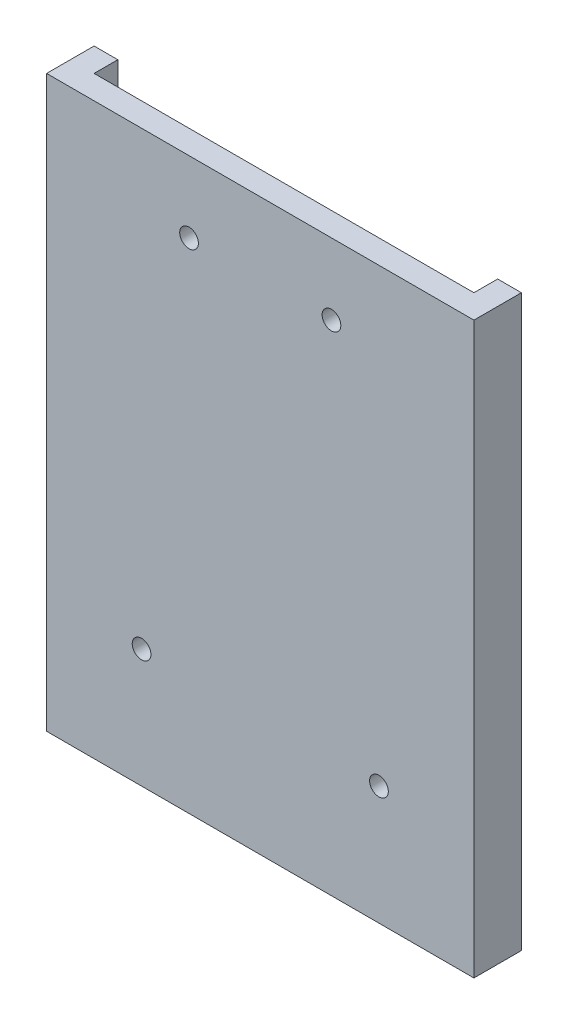
from build123d import *

# Parameters (mm, degrees)
SKETCH1_W           = 57.15
SKETCH1_H           = 6.35
BOSS_EXTRUDE1_DEPTH = 76.2
SKETCH2_W           = 50.8
SKETCH2_H           = 3.175
CUT_EXTRUDE1_DEPTH  = 73.025
SKETCH4_R           = 1.25
CUT_EXTRUDE2_DEPTH  = 4.175


with BuildPart() as part:
    # Sketch1 → Boss-Extrude1 (new body)
    with BuildSketch(Plane(origin=(0, 0, 0), x_dir=(1, 0, 0), z_dir=(0, 1, 0))):
        Rectangle(SKETCH1_W, SKETCH1_H)
    extrude(amount=BOSS_EXTRUDE1_DEPTH)

    # Sketch2 → Cut-Extrude1 (cut)
    with BuildSketch(Plane(origin=(0, 76.2, 0), x_dir=(1, 0, 0), z_dir=(0, 1, 0))):
        with Locations((0, 1.5875)):
            Rectangle(SKETCH2_W, SKETCH2_H)
    extrude(amount=-CUT_EXTRUDE1_DEPTH, mode=Mode.SUBTRACT)

    # Sketch4 → Cut-Extrude2 (cut, through all)
    with BuildSketch(Plane(origin=(0, 0, 0), x_dir=(-1, 0, 0), z_dir=(0, 0, -1))):
        with Locations((-9.525, 66.675)):
            Circle(SKETCH4_R)
        with Locations((9.525, 66.675)):
            Circle(SKETCH4_R)
        with Locations((-15.875, 15.875)):
            Circle(SKETCH4_R)
        with Locations((15.875, 15.875)):
            Circle(SKETCH4_R)
    extrude(amount=-CUT_EXTRUDE2_DEPTH, mode=Mode.SUBTRACT)


solid = part.part
